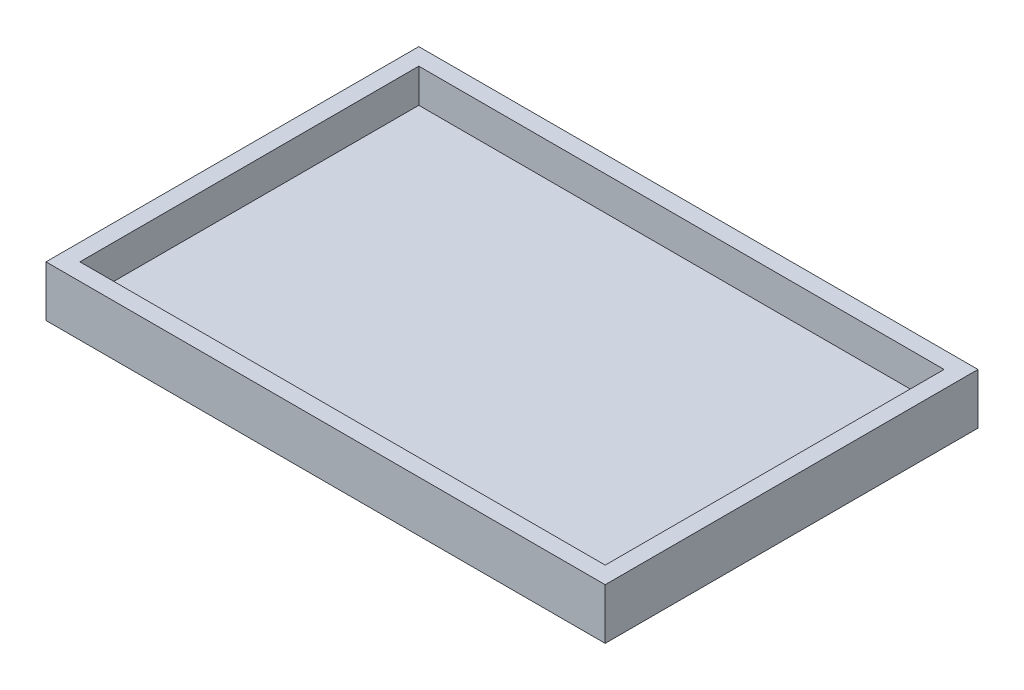
from build123d import *

# Parameters (mm, degrees)
SKETCH_1_W          = 66
SKETCH_1_H          = 44
EXTRUDE_1_DEPTH     = 6
SKETCH_2_W          = 62
SKETCH_2_H          = 40
CUT_EXTRUDE_1_DEPTH = 4


with BuildPart() as part:
    # 草图1 → 凸台-拉伸1 (new body)
    with BuildSketch(Plane(origin=(0, 0, 0), x_dir=(1, 0, 0), z_dir=(0, 1, 0))):
        with Locations((33, 22)):
            Rectangle(SKETCH_1_W, SKETCH_1_H)
    extrude(amount=EXTRUDE_1_DEPTH)

    # 草图2 → 切除-拉伸1 (cut)
    with BuildSketch(Plane(origin=(0, 6, 0), x_dir=(1, 0, 0), z_dir=(0, 1, 0))):
        with Locations((33, 22)):
            Rectangle(SKETCH_2_W, SKETCH_2_H)
    extrude(amount=-CUT_EXTRUDE_1_DEPTH, mode=Mode.SUBTRACT)


solid = part.part
